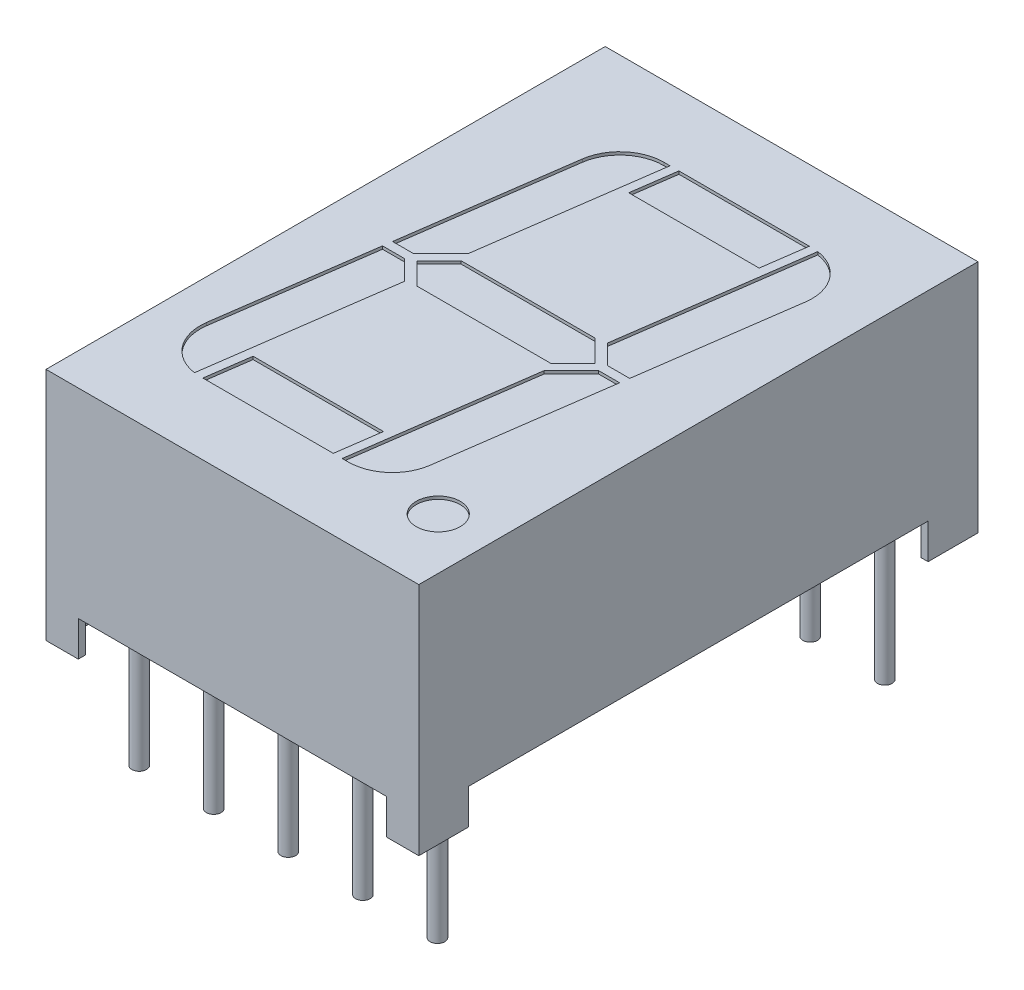
from build123d import *

# Parameters (mm, degrees)
SKETCH1_W          = 12.7
SKETCH1_H          = 19.05
EXTRUDE2_DEPTH     = 8
SKETCH2_W          = 10.5
SKETCH2_H          = 1.2
CUT_EXTRUDE2_DEPTH = 20.05
SKETCH3_W          = 15.65
SKETCH3_H          = 1.2
CUT_EXTRUDE3_DEPTH = 13.7
SKETCH5_R          = 0.25
EXTRUDE3_DEPTH     = 1.2
SKETCH5_5_R        = 0.25
EXTRUDE4_DEPTH     = 4
SKETCH1_4_R        = 0.75
CUT_EXTRUDE4_DEPTH = 0.1
SKETCH5_6_W        = 0.85
SKETCH5_6_H        = 1.45
CUT_EXTRUDE6_DEPTH = 1.2
SKETCH6_W          = 0.025316456
SKETCH6_H          = 0.026582279
CUT_EXTRUDE7_DEPTH = 0.01


with BuildPart() as part:
    # Sketch1 → Extrude2 (new body)
    with BuildSketch(Plane(origin=(0, 0, 0), x_dir=(1, 0, 0), z_dir=(0, 1, 0))):
        Rectangle(SKETCH1_W, SKETCH1_H)
    extrude(amount=-EXTRUDE2_DEPTH)

    # Sketch2 → Cut-Extrude2 (cut, through all)
    with BuildSketch(Plane.XY.offset(9.525)):
        with Locations((0, -7.4)):
            Rectangle(SKETCH2_W, SKETCH2_H)
    extrude(amount=-CUT_EXTRUDE2_DEPTH, mode=Mode.SUBTRACT)

    # Sketch3 → Cut-Extrude3 (cut, through all)
    with BuildSketch(Plane(origin=(6.35, 0, 0), x_dir=(0, 0, -1), z_dir=(1, 0, 0))):
        with Locations((0, -7.4)):
            Rectangle(SKETCH3_W, SKETCH3_H)
    extrude(amount=-CUT_EXTRUDE3_DEPTH, mode=Mode.SUBTRACT)

    # Sketch5 → Extrude3 (add)
    with BuildSketch(Plane.XZ.offset(8)):
        with Locations((-5.08, 7.62)):
            Circle(SKETCH5_R)
        with Locations((-2.54, 7.62)):
            Circle(SKETCH5_R)
        with Locations((0, 7.62)):
            Circle(SKETCH5_R)
        with Locations((2.54, 7.62)):
            Circle(SKETCH5_R)
        with Locations((5.08, 7.62)):
            Circle(SKETCH5_R)
        with Locations(Location((5.08, -7.62, 0), (0, 0, 180))):  # turned: the seam where the file's is
            Circle(SKETCH5_R)
        with Locations(Location((2.54, -7.62, 0), (0, 0, 180))):  # turned: the seam where the file's is
            Circle(SKETCH5_R)
        with Locations(Location((0, -7.62, 0), (0, 0, 180))):  # turned: the seam where the file's is
            Circle(SKETCH5_R)
        with Locations(Location((-2.54, -7.62, 0), (0, 0, 180))):  # turned: the seam where the file's is
            Circle(SKETCH5_R)
        with Locations(Location((-5.08, -7.62, 0), (0, 0, 180))):  # turned: the seam where the file's is
            Circle(SKETCH5_R)
    extrude(amount=-EXTRUDE3_DEPTH)

    # Sketch5_5 → Extrude4 (add)
    with BuildSketch(Plane.XZ.offset(8)):
        with Locations((-5.08, 7.62)):
            Circle(SKETCH5_5_R)
        with Locations((-2.54, 7.62)):
            Circle(SKETCH5_5_R)
        with Locations((0, 7.62)):
            Circle(SKETCH5_5_R)
        with Locations((2.54, 7.62)):
            Circle(SKETCH5_5_R)
        with Locations((5.08, 7.62)):
            Circle(SKETCH5_5_R)
        with Locations(Location((5.08, -7.62, 0), (0, 0, 180))):  # turned: the seam where the file's is
            Circle(SKETCH5_5_R)
        with Locations(Location((2.54, -7.62, 0), (0, 0, 180))):  # turned: the seam where the file's is
            Circle(SKETCH5_5_R)
        with Locations(Location((0, -7.62, 0), (0, 0, 180))):  # turned: the seam where the file's is
            Circle(SKETCH5_5_R)
        with Locations(Location((-2.54, -7.62, 0), (0, 0, 180))):  # turned: the seam where the file's is
            Circle(SKETCH5_5_R)
        with Locations(Location((-5.08, -7.62, 0), (0, 0, 180))):  # turned: the seam where the file's is
            Circle(SKETCH5_5_R)
    extrude(amount=EXTRUDE4_DEPTH)

    # Sketch1_4 → Cut-Extrude4 (cut)
    with BuildSketch(Plane(origin=(0, 0, 0), x_dir=(1, 0, 0), z_dir=(0, 1, 0))):
        Polygon((-1.633862278, 5.61), (2.809378503, 5.61), (3.020188437, 7.11), (-1.423052344, 7.11), align=None)
        with BuildLine():
            Line((3.112326738, 5.61), (2.43839288, 0.814681459))
            Line((2.43839288, 0.814681459), (2.503074451, 0.75))
            Line((2.503074451, 0.75), (3.944043726, 0.75))
            Line((3.944043726, 0.75), (4.597729021, 5.401241628))
            ThreePointArc((4.597729021, 5.401241628), (4.310279226, 6.512723567), (3.32108511, 7.095402283))
            Line((3.32108511, 7.095402283), (3.112326738, 5.61))
        make_face()
        with BuildLine():
            Line((2.171957051, -1.081119824), (1.535468429, -5.61))
            Line((1.535468429, -5.61), (1.324658495, -7.11))
            Line((1.324658495, -7.11), (1.535468429, -7.11))
            ThreePointArc((1.535468429, -7.11), (2.519557461, -6.742063946), (3.020870712, -5.818758372))
            Line((3.020870712, -5.818758372), (3.733233792, -0.75))
            Line((3.733233792, -0.75), (2.503076304, -0.75))
            Line((2.503076304, -0.75), (2.171957051, -1.081119824))
        make_face()
        Polygon((3.103075271, -0.15), (2.503076304, -0.75), (3.733233792, -0.75), (3.817557766, -0.15), align=None)
        Polygon((3.103075485, 0.15), (3.859719753, 0.15), (3.944043726, 0.75), (2.503074451, 0.75), align=None)
        Polygon((1.02171026, -7.11), (1.232520194, -5.61), (-3.210720587, -5.61), (-3.421530521, -7.11), align=None)
        with BuildLine():
            Line((-3.722427194, -7.095402283), (-3.513668822, -5.61))
            Line((-3.513668822, -5.61), (-2.839734964, -0.814681459))
            Line((-2.839734964, -0.814681459), (-2.904416535, -0.75))
            Line((-2.904416535, -0.75), (-4.34538581, -0.75))
            Line((-4.34538581, -0.75), (-4.999071105, -5.401241628))
            ThreePointArc((-4.999071105, -5.401241628), (-4.711621309, -6.512723567), (-3.722427194, -7.095402283))
        make_face()
        Polygon((-4.34538581, -0.75), (-2.904416535, -0.75), (-3.504417568, -0.15), (-4.261061836, -0.15), align=None)
        Polygon((-3.504417354, 0.15), (-2.904418388, 0.75), (-4.134575876, 0.75), (-4.218899849, 0.15), align=None)
        with BuildLine():
            Line((-2.904418388, 0.75), (-2.573299135, 1.081119824))
            Line((-2.573299135, 1.081119824), (-1.936810513, 5.61))
            Line((-1.936810513, 5.61), (-1.726000579, 7.11))
            Line((-1.726000579, 7.11), (-1.936810513, 7.11))
            ThreePointArc((-1.936810513, 7.11), (-2.920899544, 6.742063946), (-3.422212796, 5.818758372))
            Line((-3.422212796, 5.818758372), (-4.134575876, 0.75))
            Line((-4.134575876, 0.75), (-2.904418388, 0.75))
        make_face()
        Polygon((2.078812601, -0.75), (2.241333309, -0.587479012), (2.38611412, 0.442696426), (2.078810017, 0.75), (-2.480154685, 0.75), (-2.642675393, 0.587479012), (-2.787456204, -0.442696426), (-2.4801521, -0.75), align=None)
        Polygon((2.38611412, 0.442696426), (2.241333309, -0.587479012), (2.828811309, 0), align=None)
        Polygon((-3.230153393, 0), (-2.787456204, -0.442696426), (-2.642675393, 0.587479012), align=None)
        with Locations(Location((4.597729021, -7.11, 0), (0, 0, 270))):  # turned: the seam where the file's is
            Circle(SKETCH1_4_R)
    extrude(amount=-CUT_EXTRUDE4_DEPTH, mode=Mode.SUBTRACT)

    # Sketch5_6 → Cut-Extrude6 (cut)
    with BuildSketch(Plane.XZ.offset(8)):
        with Locations((-5.675, 8.55)):
            Rectangle(SKETCH5_6_W, SKETCH5_6_H)
        with Locations((5.675, 8.55)):
            Rectangle(SKETCH5_6_W, SKETCH5_6_H)
        with Locations((5.675, -8.55)):
            Rectangle(SKETCH5_6_W, SKETCH5_6_H)
        with Locations((-5.675, -8.55)):
            Rectangle(SKETCH5_6_W, SKETCH5_6_H)
    extrude(amount=-CUT_EXTRUDE6_DEPTH, mode=Mode.SUBTRACT)

    # Sketch6 → Cut-Extrude7 (cut)
    with BuildSketch(Plane.XZ.offset(6.8)):
        Polygon((-0.572151899, -6.266957949), (-0.595609177, -6.341641494), (-0.620352057, -6.341641494), (-0.636768196, -6.291305259), (-0.652294304, -6.341641494), (-0.678026108, -6.341641494), (-0.701265823, -6.266957949), (-0.676087816, -6.266957949), (-0.663093354, -6.318441335), (-0.646677215, -6.266957949), (-0.625178006, -6.266957949), (-0.608860759, -6.318441335), (-0.596044304, -6.266957949), align=None)
        Polygon((-0.437974684, -6.266957949), (-0.461431962, -6.341641494), (-0.486174842, -6.341641494), (-0.502590981, -6.291305259), (-0.518117089, -6.341641494), (-0.543848892, -6.341641494), (-0.567088608, -6.266957949), (-0.541910601, -6.266957949), (-0.528916139, -6.318441335), (-0.5125, -6.266957949), (-0.491000791, -6.266957949), (-0.474683544, -6.318441335), (-0.461867089, -6.266957949), align=None)
        Polygon((-0.303797468, -6.266957949), (-0.327254747, -6.341641494), (-0.351997627, -6.341641494), (-0.368413766, -6.291305259), (-0.383939873, -6.341641494), (-0.409671677, -6.341641494), (-0.432911392, -6.266957949), (-0.407733386, -6.266957949), (-0.394738924, -6.318441335), (-0.378322785, -6.266957949), (-0.356823576, -6.266957949), (-0.340506329, -6.318441335), (-0.327689873, -6.266957949), align=None)
        with Locations((-0.275949367, -6.328350355)):
            Rectangle(SKETCH6_W, SKETCH6_H)
        with BuildLine():
            add(Edge.make_bspline(
                [(-0.159493671, -6.310470607), (-0.15953016, -6.311692749), (-0.159601812, -6.314092627), (-0.16021153, -6.317600205), (-0.161205016, -6.32092491), (-0.162579134, -6.324087571), (-0.164367936, -6.32706619), (-0.166577526, -6.329846467), (-0.169141939, -6.332481267), (-0.172108149, -6.334887397), (-0.175388259, -6.337091773), (-0.178985835, -6.338988773), (-0.182864539, -6.340585255), (-0.187013125, -6.341923807), (-0.191459564, -6.342912387), (-0.196177094, -6.343636333), (-0.201170512, -6.344109663), (-0.20459409, -6.344151629), (-0.206348892, -6.344173139)],
                knots=[0, 0, 0, 0, 0.907352243, 1.781736951, 2.63548328, 3.47985091, 4.336556021, 5.208523475, 6.112432747, 7.062451073, 8.040435374, 9.043840564, 10.077958095, 11.152835584, 12.277940427, 13.457536469, 14.696825396, 16, 16, 16, 16], degree=3))
            add(Edge.make_bspline(
                [(-0.206348892, -6.344173139), (-0.208367148, -6.344149067), (-0.21227633, -6.344102443), (-0.217939855, -6.343673844), (-0.223207892, -6.343027704), (-0.228103607, -6.342061162), (-0.232708206, -6.340860397), (-0.237141474, -6.339569106), (-0.241422786, -6.33810469), (-0.244195876, -6.337004532), (-0.24556962, -6.336459532)],
                knots=[0, 0, 0, 0, 1.203215828, 2.33052265, 3.384689099, 4.366106119, 5.303329643, 6.221311756, 7.118865988, 8, 8, 8, 8], degree=3))
            Line((-0.24556962, -6.336459532), (-0.24556962, -6.31252757))
            Line((-0.24556962, -6.31252757), (-0.242721519, -6.31252757))
            add(Edge.make_bspline(
                [(-0.242721519, -6.31252757), (-0.241356205, -6.313609025), (-0.238633592, -6.315765585), (-0.234200359, -6.318528191), (-0.229552713, -6.320930354), (-0.224707243, -6.322904355), (-0.219810398, -6.324490679), (-0.21493502, -6.325584207), (-0.210169433, -6.326331556), (-0.207010864, -6.326412062), (-0.205458861, -6.32645162)],
                knots=[0, 0, 0, 0, 1.030622468, 2.055194264, 3.087043286, 4.125157485, 5.149848264, 6.130935704, 7.081611712, 8, 8, 8, 8], degree=3))
            add(Edge.make_bspline(
                [(-0.205458861, -6.32645162), (-0.205030085, -6.326450697), (-0.204112108, -6.326448719), (-0.202650581, -6.326320992), (-0.20099877, -6.326225415), (-0.199226261, -6.326018231), (-0.197429535, -6.325796371), (-0.195767134, -6.325421446), (-0.194257539, -6.325056578), (-0.193351018, -6.324688581), (-0.192919304, -6.324513329)],
                knots=[0, 0, 0, 0, 0.806402781, 1.726445712, 2.758724871, 3.919014682, 5.083870887, 6.16165551, 7.124521387, 8, 8, 8, 8], degree=3))
            add(Edge.make_bspline(
                [(-0.192919304, -6.324513329), (-0.192439741, -6.324285187), (-0.191497298, -6.32383684), (-0.190203698, -6.323026521), (-0.189036018, -6.322143056), (-0.187978647, -6.321178126), (-0.187104366, -6.320012376), (-0.186480499, -6.318603703), (-0.186135606, -6.316954685), (-0.186096583, -6.315779482), (-0.186075949, -6.315158107)],
                knots=[0, 0, 0, 0, 1.024747072, 2.013846092, 2.940605744, 3.850156746, 4.769278501, 5.73222711, 6.800942666, 8, 8, 8, 8], degree=3))
            add(Edge.make_bspline(
                [(-0.186075949, -6.315158107), (-0.186107794, -6.31461247), (-0.18617041, -6.313539586), (-0.186747603, -6.312004472), (-0.187657041, -6.310595304), (-0.188938631, -6.309326529), (-0.190531807, -6.308176995), (-0.192474191, -6.30719469), (-0.194724312, -6.306321502), (-0.196368382, -6.305903525), (-0.197231013, -6.305684215)],
                knots=[0, 0, 0, 0, 0.82557554, 1.623324704, 2.456147571, 3.35491006, 4.343819762, 5.427079081, 6.650009487, 8, 8, 8, 8], degree=3))
            add(Edge.make_bspline(
                [(-0.197231013, -6.305684215), (-0.199199639, -6.305235975), (-0.203238649, -6.304316325), (-0.209388473, -6.30317757), (-0.215516824, -6.30190271), (-0.219469591, -6.300696067), (-0.221400316, -6.300106683)],
                knots=[0, 0, 0, 0, 0.976100998, 2.002656142, 3.024398856, 4, 4, 4, 4], degree=3))
            add(Edge.make_bspline(
                [(-0.221400316, -6.300106683), (-0.222438835, -6.299753693), (-0.224460408, -6.299066565), (-0.227351919, -6.297904905), (-0.230013147, -6.296635076), (-0.23245286, -6.295279521), (-0.234653549, -6.293806981), (-0.236647817, -6.292265603), (-0.238410933, -6.290625564), (-0.239957738, -6.288885797), (-0.241282641, -6.287035094), (-0.242435025, -6.285089897), (-0.243417646, -6.283034477), (-0.244195684, -6.280864254), (-0.244820323, -6.278590599), (-0.245239305, -6.276212887), (-0.245538322, -6.273729758), (-0.245559046, -6.272035373), (-0.24556962, -6.271170766)],
                knots=[0, 0, 0, 0, 1.287047841, 2.5053592, 3.654260482, 4.74538952, 5.777514103, 6.75871007, 7.700244599, 8.599107454, 9.48590269, 10.366941872, 11.24940663, 12.154970331, 13.068988358, 14.012872203, 14.986013017, 16, 16, 16, 16], degree=3))
            add(Edge.make_bspline(
                [(-0.24556962, -6.271170766), (-0.245532318, -6.270014621), (-0.245458909, -6.267739349), (-0.24485748, -6.264410304), (-0.24383089, -6.261261568), (-0.242444827, -6.258258105), (-0.240616199, -6.255445019), (-0.238431404, -6.252766471), (-0.235807357, -6.25029488), (-0.232830235, -6.247994546), (-0.229542851, -6.245915148), (-0.226003867, -6.244084591), (-0.222234578, -6.24254794), (-0.218249032, -6.241274046), (-0.214030563, -6.240319375), (-0.20959333, -6.239600443), (-0.204919541, -6.239187262), (-0.20172812, -6.239136011), (-0.200098892, -6.239109848)],
                knots=[0, 0, 0, 0, 0.894990994, 1.761326291, 2.609044902, 3.454222546, 4.315366365, 5.200560057, 6.125081389, 7.100429509, 8.110379559, 9.133447974, 10.182136699, 11.259192205, 12.370181258, 13.528580438, 14.738335141, 16, 16, 16, 16], degree=3))
            add(Edge.make_bspline(
                [(-0.200098892, -6.239109848), (-0.198430198, -6.239132001), (-0.19509564, -6.239176269), (-0.1901143, -6.239554826), (-0.185159872, -6.240107138), (-0.180297448, -6.240956378), (-0.175605285, -6.24192461), (-0.17118617, -6.243023883), (-0.167106618, -6.244261389), (-0.164532965, -6.245215791), (-0.163291139, -6.245676304)],
                knots=[0, 0, 0, 0, 1.065407564, 2.129008667, 3.188544425, 4.247469455, 5.279542408, 6.247502114, 7.154394069, 8, 8, 8, 8], degree=3))
            Line((-0.163291139, -6.245676304), (-0.163291139, -6.268223772))
            Line((-0.163291139, -6.268223772), (-0.166119462, -6.268223772))
            add(Edge.make_bspline(
                [(-0.166119462, -6.268223772), (-0.167192966, -6.267424484), (-0.169383743, -6.265793319), (-0.173033347, -6.263691583), (-0.177000967, -6.261751492), (-0.181282594, -6.260059835), (-0.185742374, -6.258601828), (-0.190325133, -6.25758227), (-0.194951348, -6.256940562), (-0.198053052, -6.256867774), (-0.19960443, -6.256831367)],
                knots=[0, 0, 0, 0, 0.892265782, 1.820912499, 2.804518821, 3.836954028, 4.889985052, 5.931488012, 6.965393252, 8, 8, 8, 8], degree=3))
            add(Edge.make_bspline(
                [(-0.19960443, -6.256831367), (-0.200700035, -6.25685327), (-0.202897679, -6.256897203), (-0.20616687, -6.257282089), (-0.209407348, -6.257920942), (-0.21144203, -6.258736994), (-0.212460443, -6.259145449)],
                knots=[0, 0, 0, 0, 0.999122297, 2.004111588, 3.001004448, 4, 4, 4, 4], degree=3))
            add(Edge.make_bspline(
                [(-0.212460443, -6.259145449), (-0.212894173, -6.259346628), (-0.213761342, -6.259748852), (-0.214968884, -6.260528478), (-0.216089856, -6.261444821), (-0.217085439, -6.262497578), (-0.217929873, -6.263665932), (-0.218548899, -6.264933514), (-0.218923392, -6.266297396), (-0.218965739, -6.267232495), (-0.218987342, -6.267709532)],
                knots=[0, 0, 0, 0, 1.004925302, 2.009180302, 3.014392739, 4.04465309, 5.049195417, 6.035570224, 6.99785458, 8, 8, 8, 8], degree=3))
            add(Edge.make_bspline(
                [(-0.218987342, -6.267709532), (-0.218952904, -6.268347697), (-0.218887095, -6.269567173), (-0.218280511, -6.271282968), (-0.217295678, -6.272761402), (-0.216135073, -6.273756322), (-0.215017943, -6.27445376), (-0.213982284, -6.274964271), (-0.212773057, -6.27544763), (-0.211401809, -6.275945098), (-0.209865482, -6.276436286), (-0.208156925, -6.276911832), (-0.206274208, -6.277361128), (-0.204958333, -6.277647319), (-0.204272152, -6.277796557)],
                knots=[0, 0, 0, 0, 1.173816843, 2.243057204, 3.312297565, 4.415174738, 5.03266065, 5.73970059, 6.541434878, 7.433956553, 8.430083051, 9.515931566, 10.70464786, 12, 12, 12, 12], degree=3))
            add(Edge.make_bspline(
                [(-0.204272152, -6.277796557), (-0.202439229, -6.278172002), (-0.198844263, -6.278908373), (-0.193445039, -6.280020738), (-0.187940051, -6.281286097), (-0.184268899, -6.282438093), (-0.182357595, -6.283037854)],
                knots=[0, 0, 0, 0, 0.995749986, 1.952994291, 2.934271555, 4, 4, 4, 4], degree=3))
            add(Edge.make_bspline(
                [(-0.182357595, -6.283037854), (-0.181411107, -6.283357213), (-0.179559623, -6.283981931), (-0.176918075, -6.285066615), (-0.174469022, -6.286248704), (-0.172190751, -6.28747119), (-0.17012867, -6.288834407), (-0.168235447, -6.290249054), (-0.166552428, -6.291777163), (-0.165054478, -6.293390021), (-0.163736077, -6.295100454), (-0.162601114, -6.296938556), (-0.161637968, -6.298893085), (-0.160829836, -6.300966157), (-0.16025182, -6.303173225), (-0.159817762, -6.305499525), (-0.15952694, -6.307944841), (-0.159504884, -6.309619287), (-0.159493671, -6.310470607)],
                knots=[0, 0, 0, 0, 1.237386967, 2.420528625, 3.534815053, 4.605870898, 5.620827102, 6.594482803, 7.531295079, 8.432978826, 9.318460435, 10.202471551, 11.10474705, 12.014900263, 12.954095338, 13.926516828, 14.945802342, 16, 16, 16, 16], degree=3))
        make_face()
        with BuildLine():
            Line((-0.067088608, -6.341641494), (-0.091139241, -6.341641494))
            Line((-0.091139241, -6.341641494), (-0.091139241, -6.333809215))
            add(Edge.make_bspline(
                [(-0.091139241, -6.333809215), (-0.092232496, -6.334617882), (-0.094340276, -6.336176981), (-0.097514015, -6.338255745), (-0.100542736, -6.340038907), (-0.103464337, -6.34158106), (-0.106479693, -6.342771907), (-0.109707195, -6.343593763), (-0.113209459, -6.344094883), (-0.115636434, -6.344146474), (-0.116890823, -6.344173139)],
                knots=[0, 0, 0, 0, 1.150906677, 2.218931226, 3.20955724, 4.125565256, 5.012676028, 5.946647191, 6.938718366, 8, 8, 8, 8], degree=3))
            add(Edge.make_bspline(
                [(-0.116890823, -6.344173139), (-0.117907168, -6.34415041), (-0.119886286, -6.34410615), (-0.122763616, -6.343761412), (-0.125470927, -6.343223266), (-0.127987077, -6.34241741), (-0.130352422, -6.341443293), (-0.132503941, -6.340184206), (-0.13449163, -6.338724869), (-0.136295007, -6.337047933), (-0.137885627, -6.335126971), (-0.139272677, -6.333004221), (-0.140448489, -6.330669582), (-0.141390127, -6.328118215), (-0.142145061, -6.325359771), (-0.142669038, -6.322380564), (-0.142989618, -6.319193425), (-0.143021559, -6.316998296), (-0.143037975, -6.315870133)],
                knots=[0, 0, 0, 0, 1.108935798, 2.159418225, 3.158520219, 4.116592843, 5.038730546, 5.944611115, 6.829677354, 7.725673622, 8.624842385, 9.544872214, 10.487719724, 11.471363217, 12.50822837, 13.604887271, 14.769056852, 16, 16, 16, 16], degree=3))
            Line((-0.143037975, -6.315870133), (-0.143037975, -6.266957949))
            Line((-0.143037975, -6.266957949), (-0.118987342, -6.266957949))
            Line((-0.118987342, -6.266957949), (-0.118987342, -6.304537063))
            add(Edge.make_bspline(
                [(-0.118987342, -6.304537063), (-0.118985706, -6.305453534), (-0.118982576, -6.30720775), (-0.118900237, -6.309713556), (-0.118779336, -6.311981729), (-0.118640631, -6.314023758), (-0.118387615, -6.315870508), (-0.118009906, -6.317536669), (-0.11753908, -6.319056271), (-0.117074761, -6.319962973), (-0.116851266, -6.320399405)],
                knots=[0, 0, 0, 0, 1.361401701, 2.605856924, 3.723918663, 4.735739235, 5.645738665, 6.489217889, 7.27279937, 8, 8, 8, 8], degree=3))
            add(Edge.make_bspline(
                [(-0.116851266, -6.320399405), (-0.116621226, -6.320798053), (-0.116168987, -6.32158176), (-0.115249176, -6.322588908), (-0.114173193, -6.323425814), (-0.112903555, -6.324098458), (-0.111410474, -6.324582162), (-0.109678473, -6.324928909), (-0.107692458, -6.325142732), (-0.106283538, -6.325170895), (-0.105537975, -6.325185797)],
                knots=[0, 0, 0, 0, 0.849057291, 1.669173542, 2.503217716, 3.359509317, 4.311793648, 5.394940091, 6.621469141, 8, 8, 8, 8], degree=3))
            add(Edge.make_bspline(
                [(-0.105537975, -6.325185797), (-0.10499671, -6.32516834), (-0.103883832, -6.325132446), (-0.102178621, -6.324902518), (-0.100389592, -6.324540862), (-0.097875395, -6.323881838), (-0.09469925, -6.32270266), (-0.092335111, -6.321343858), (-0.091139241, -6.320656525)],
                knots=[0, 0, 0, 0, 0.638164724, 1.312110757, 2.025558264, 2.789159289, 4.375836335, 6, 6, 6, 6], degree=3))
            Line((-0.091139241, -6.320656525), (-0.091139241, -6.266957949))
            Line((-0.091139241, -6.266957949), (-0.067088608, -6.266957949))
            Line((-0.067088608, -6.266957949), (-0.067088608, -6.341641494))
        make_face()
        with BuildLine():
            Line((0.030379747, -6.341641494), (0.006329114, -6.341641494))
            Line((0.006329114, -6.341641494), (0.006329114, -6.30406238))
            add(Edge.make_bspline(
                [(0.006329114, -6.30406238), (0.00630879, -6.302531906), (0.006268255, -6.299479494), (0.005934675, -6.295722718), (0.005600966, -6.292874928), (0.005224143, -6.291038861), (0.004793956, -6.289490525), (0.00438151, -6.288604787), (0.004193038, -6.288200038)],
                knots=[0, 0, 0, 0, 1.709235885, 3.408940626, 4.211008593, 4.910095588, 5.501954032, 6, 6, 6, 6], degree=3))
            add(Edge.make_bspline(
                [(0.004193038, -6.288200038), (0.00394861, -6.287801915), (0.003469373, -6.28702134), (0.002531558, -6.286009318), (0.001434909, -6.285173105), (0.000156185, -6.284508155), (-0.001328468, -6.284022257), (-0.003041142, -6.283635598), (-0.005027113, -6.283467038), (-0.006434481, -6.283432128), (-0.007179589, -6.283413645)],
                knots=[0, 0, 0, 0, 0.860145871, 1.686437142, 2.528070002, 3.393017362, 4.331453407, 5.402595683, 6.624848233, 8, 8, 8, 8], degree=3))
            add(Edge.make_bspline(
                [(-0.007179589, -6.283413645), (-0.008311478, -6.283470226), (-0.010622712, -6.283585759), (-0.013484003, -6.284299351), (-0.015810878, -6.285111648), (-0.017656499, -6.285885885), (-0.019573028, -6.28684051), (-0.020856452, -6.287567584), (-0.021518987, -6.287942918)],
                knots=[0, 0, 0, 0, 1.338419466, 2.732951426, 3.468143565, 4.254837763, 5.099104234, 6, 6, 6, 6], degree=3))
            Line((-0.021518987, -6.287942918), (-0.021518987, -6.341641494))
            Line((-0.021518987, -6.341641494), (-0.04556962, -6.341641494))
            Line((-0.04556962, -6.341641494), (-0.04556962, -6.266957949))
            Line((-0.04556962, -6.266957949), (-0.021518987, -6.266957949))
            Line((-0.021518987, -6.266957949), (-0.021518987, -6.274790228))
            add(Edge.make_bspline(
                [(-0.021518987, -6.274790228), (-0.02046175, -6.27398379), (-0.018403774, -6.272414011), (-0.015227022, -6.270380601), (-0.01215631, -6.268570745), (-0.009101788, -6.267058611), (-0.005977291, -6.26586001), (-0.00270966, -6.265044407), (0.000707053, -6.264501459), (0.003043726, -6.264451647), (0.004232595, -6.264426304)],
                knots=[0, 0, 0, 0, 1.126064518, 2.191951536, 3.19307265, 4.144813015, 5.076393104, 6.021983703, 6.993610568, 8, 8, 8, 8], degree=3))
            add(Edge.make_bspline(
                [(0.004232595, -6.264426304), (0.005228866, -6.264451693), (0.007173765, -6.264501257), (0.010008526, -6.264810966), (0.012679947, -6.26536163), (0.015172222, -6.26615946), (0.017514838, -6.267145073), (0.019676795, -6.268376583), (0.021668821, -6.269835023), (0.02349739, -6.271495964), (0.025127571, -6.273385922), (0.026547057, -6.275502295), (0.02771848, -6.277851024), (0.028727312, -6.28039816), (0.029461537, -6.283175931), (0.029987988, -6.286166697), (0.030338418, -6.289371879), (0.030365695, -6.291587779), (0.030379747, -6.29272931)],
                knots=[0, 0, 0, 0, 1.088441561, 2.124831547, 3.110816719, 4.062969431, 4.979391633, 5.88258537, 6.774334107, 7.671621258, 8.575503974, 9.49441354, 10.447872957, 11.437639084, 12.482478955, 13.580222388, 14.753440527, 16, 16, 16, 16], degree=3))
            Line((0.030379747, -6.29272931), (0.030379747, -6.341641494))
        make_face()
        Polygon((0.125316456, -6.341641494), (0.053164557, -6.341641494), (0.053164557, -6.241641494), (0.078481013, -6.241641494), (0.078481013, -6.322654152), (0.125316456, -6.322654152), align=None)
        Polygon((0.212658228, -6.341641494), (0.140506329, -6.341641494), (0.140506329, -6.241641494), (0.212658228, -6.241641494), (0.212658228, -6.260628835), (0.165822785, -6.260628835), (0.165822785, -6.278350354), (0.208860759, -6.278350354), (0.208860759, -6.297337696), (0.165822785, -6.297337696), (0.165822785, -6.322654152), (0.212658228, -6.322654152), align=None)
        with BuildLine():
            add(Edge.make_bspline(
                [(0.329113924, -6.291740386), (0.329094609, -6.292888075), (0.329056357, -6.295160961), (0.328761165, -6.298525768), (0.32823514, -6.301791443), (0.327555959, -6.304975692), (0.326633453, -6.308054619), (0.325551739, -6.311062196), (0.324242093, -6.31396769), (0.322737241, -6.316769124), (0.321087768, -6.319441227), (0.319313019, -6.321961436), (0.31746724, -6.324344654), (0.315477927, -6.326539548), (0.313398746, -6.328581567), (0.311223217, -6.330472381), (0.308918153, -6.332175812), (0.30731099, -6.333198697), (0.30650712, -6.333710323)],
                knots=[0, 0, 0, 0, 1.105570398, 2.18947457, 3.250358341, 4.290584537, 5.323553275, 6.344225964, 7.367641686, 8.3905646, 9.405808457, 10.390761353, 11.358902336, 12.307789878, 13.241960776, 14.165076779, 15.082208636, 16, 16, 16, 16], degree=3))
            add(Edge.make_bspline(
                [(0.30650712, -6.333710323), (0.305267899, -6.334422492), (0.302783134, -6.335850466), (0.298799188, -6.337518597), (0.294668069, -6.338926553), (0.290309515, -6.339974743), (0.285663167, -6.340703476), (0.28066851, -6.341266526), (0.275267382, -6.341566891), (0.2715325, -6.341616059), (0.269600475, -6.341641494)],
                knots=[0, 0, 0, 0, 0.896298978, 1.797171328, 2.70531317, 3.633678302, 4.606491125, 5.655688921, 6.787306437, 8, 8, 8, 8], degree=3))
            Line((0.269600475, -6.341641494), (0.234177215, -6.341641494))
            Line((0.234177215, -6.341641494), (0.234177215, -6.241641494))
            Line((0.234177215, -6.241641494), (0.270609177, -6.241641494))
            add(Edge.make_bspline(
                [(0.270609177, -6.241641494), (0.272587901, -6.241658189), (0.276404614, -6.241690392), (0.281915032, -6.242106361), (0.287013411, -6.242705881), (0.291697991, -6.243632573), (0.296006397, -6.244741224), (0.299937419, -6.246104259), (0.303549308, -6.247602531), (0.305728136, -6.248876279), (0.306784019, -6.249493551)],
                knots=[0, 0, 0, 0, 1.267192274, 2.444256634, 3.537982003, 4.553396635, 5.500903572, 6.385021601, 7.217363933, 8, 8, 8, 8], degree=3))
            add(Edge.make_bspline(
                [(0.306784019, -6.249493551), (0.307634972, -6.250030091), (0.309327097, -6.251097005), (0.311728312, -6.252878857), (0.313957739, -6.254834934), (0.316086242, -6.256886752), (0.318066056, -6.25908964), (0.319909269, -6.261428344), (0.321613036, -6.263906451), (0.323171192, -6.266515871), (0.324591277, -6.26924611), (0.325783356, -6.272118456), (0.326822718, -6.275101329), (0.327668801, -6.278200268), (0.32832513, -6.281417658), (0.328771214, -6.284755138), (0.329054647, -6.288208327), (0.329093999, -6.29055312), (0.329113924, -6.291740386)],
                knots=[0, 0, 0, 0, 0.964043478, 1.917004671, 2.862223898, 3.805158963, 4.749279098, 5.698713747, 6.657523689, 7.629652222, 8.610369353, 9.604453025, 10.607693792, 11.636365947, 12.681120053, 13.752669011, 14.862083412, 16, 16, 16, 16], degree=3))
        make_face()
        with BuildLine():
            add(Edge.make_bspline(
                [(0.302531646, -6.291582158), (0.302521175, -6.290777445), (0.302500636, -6.289198953), (0.302312313, -6.286882777), (0.302041725, -6.284656728), (0.301652591, -6.282513095), (0.301112159, -6.280462947), (0.300479977, -6.278501378), (0.299752887, -6.276622455), (0.298871957, -6.274844795), (0.297898133, -6.273136458), (0.296750689, -6.271550931), (0.295502338, -6.270038048), (0.294124055, -6.268610062), (0.292581114, -6.267304166), (0.290921012, -6.26607409), (0.289120654, -6.264945764), (0.287847665, -6.264285715), (0.287203323, -6.26395162)],
                knots=[0, 0, 0, 0, 1.152052275, 2.259818351, 3.325348653, 4.362224493, 5.376551665, 6.358740615, 7.312387502, 8.258104984, 9.197203025, 10.124507262, 11.056413058, 12.004389423, 12.961766972, 13.947352551, 14.961020569, 16, 16, 16, 16], degree=3))
            add(Edge.make_bspline(
                [(0.287203323, -6.26395162), (0.286528425, -6.263644908), (0.285190731, -6.263036984), (0.283119908, -6.262305791), (0.281030524, -6.261732956), (0.278828925, -6.261302097), (0.276359165, -6.260980166), (0.273433583, -6.260782908), (0.269977674, -6.260640739), (0.267490959, -6.260632987), (0.266159019, -6.260628835)],
                knots=[0, 0, 0, 0, 0.826967603, 1.639107464, 2.447640171, 3.242670507, 4.14065217, 5.225198036, 6.513753944, 8, 8, 8, 8], degree=3))
            Line((0.266159019, -6.260628835), (0.259493671, -6.260628835))
            Line((0.259493671, -6.260628835), (0.259493671, -6.322654152))
            Line((0.259493671, -6.322654152), (0.266159019, -6.322654152))
            add(Edge.make_bspline(
                [(0.266159019, -6.322654152), (0.266917226, -6.322649406), (0.268380993, -6.322640244), (0.27049723, -6.32259713), (0.272463046, -6.322550416), (0.274267852, -6.322433379), (0.275920195, -6.322362879), (0.277406342, -6.322179208), (0.278743292, -6.322044733), (0.280315773, -6.321767011), (0.28217096, -6.321361036), (0.284337749, -6.320677878), (0.286478448, -6.319828304), (0.287866999, -6.319143225), (0.288568038, -6.318797348)],
                knots=[0, 0, 0, 0, 1.186805873, 2.291202465, 3.313317863, 4.264127762, 5.122212376, 5.900577546, 6.607154111, 7.224697658, 8.398873738, 9.57716935, 10.776782771, 12, 12, 12, 12], degree=3))
            add(Edge.make_bspline(
                [(0.288568038, -6.318797348), (0.289153152, -6.31845583), (0.290307072, -6.317782313), (0.291930612, -6.316648262), (0.293438202, -6.315440452), (0.294834679, -6.314152312), (0.296096265, -6.312762926), (0.297252353, -6.31130346), (0.29825774, -6.309743139), (0.299496994, -6.307554313), (0.300744084, -6.304529555), (0.301776483, -6.300556802), (0.302415631, -6.29619789), (0.302491983, -6.293160149), (0.302531646, -6.291582158)],
                knots=[0, 0, 0, 0, 0.755237594, 1.489427721, 2.205882609, 2.908165467, 3.605466573, 4.296695275, 4.981837198, 5.673065901, 7.099889822, 8.61390339, 10.241051878, 12, 12, 12, 12], degree=3))
        make_face(mode=Mode.SUBTRACT)
        with Locations((0.360759494, -6.328350355)):
            Rectangle(SKETCH6_W, SKETCH6_H)
        with BuildLine():
            add(Edge.make_bspline(
                [(0.435403481, -6.344173139), (0.433813364, -6.344151336), (0.43069222, -6.34410854), (0.426120933, -6.343631511), (0.421755567, -6.342914215), (0.417609943, -6.341891896), (0.4136994, -6.340551377), (0.41004445, -6.33888137), (0.406627778, -6.336914175), (0.404565858, -6.335329278), (0.403540348, -6.334541019)],
                knots=[0, 0, 0, 0, 1.123701398, 2.205645569, 3.245398653, 4.249180969, 5.220497262, 6.163202923, 7.086456062, 8, 8, 8, 8], degree=3))
            add(Edge.make_bspline(
                [(0.403540348, -6.334541019), (0.402588713, -6.333686186), (0.400689124, -6.331979826), (0.398221497, -6.329009282), (0.396103421, -6.325720309), (0.394291165, -6.322128656), (0.392859214, -6.318208771), (0.391866679, -6.313958876), (0.391239075, -6.309401547), (0.391173123, -6.306253342), (0.391139241, -6.304635956)],
                knots=[0, 0, 0, 0, 0.916342154, 1.829140869, 2.758848968, 3.716597128, 4.708179637, 5.743612459, 6.840783343, 8, 8, 8, 8], degree=3))
            add(Edge.make_bspline(
                [(0.391139241, -6.304635956), (0.391178001, -6.302932728), (0.391253124, -6.299631648), (0.391916883, -6.294859461), (0.392986496, -6.29044178), (0.394524054, -6.286389872), (0.396454496, -6.28269668), (0.398718989, -6.279324846), (0.401339514, -6.276281922), (0.403346653, -6.274536482), (0.404351266, -6.273662854)],
                knots=[0, 0, 0, 0, 1.171797512, 2.271099083, 3.308930235, 4.294129479, 5.24602549, 6.17106565, 7.084581485, 8, 8, 8, 8], degree=3))
            add(Edge.make_bspline(
                [(0.404351266, -6.273662854), (0.40537705, -6.272894075), (0.407441008, -6.271347232), (0.410840547, -6.26945242), (0.41445276, -6.267847903), (0.418283877, -6.266602017), (0.422264395, -6.26565348), (0.426329936, -6.264926508), (0.430476303, -6.264506483), (0.433266488, -6.264453159), (0.434671677, -6.264426304)],
                knots=[0, 0, 0, 0, 0.952097844, 1.915695341, 2.885641886, 3.886921822, 4.905719434, 5.925883802, 6.95543633, 8, 8, 8, 8], degree=3))
            add(Edge.make_bspline(
                [(0.434671677, -6.264426304), (0.435918404, -6.264443267), (0.438369891, -6.264476624), (0.441970824, -6.264799281), (0.445419409, -6.265329446), (0.448716721, -6.26607304), (0.451889869, -6.266965838), (0.454949341, -6.267997119), (0.457914157, -6.26913506), (0.459814835, -6.270019275), (0.460759494, -6.27045874)],
                knots=[0, 0, 0, 0, 1.107671842, 2.178058178, 3.209662749, 4.206063564, 5.179815947, 6.137646632, 7.07438927, 8, 8, 8, 8], degree=3))
            Line((0.460759494, -6.27045874), (0.460759494, -6.291008582))
            Line((0.460759494, -6.291008582), (0.45741693, -6.291008582))
            add(Edge.make_bspline(
                [(0.45741693, -6.291008582), (0.456918162, -6.290590355), (0.455836226, -6.289683131), (0.454034874, -6.288282119), (0.451901363, -6.286731553), (0.450250156, -6.28584555), (0.449367089, -6.285371715)],
                knots=[0, 0, 0, 0, 0.792878214, 1.719922066, 2.780612869, 4, 4, 4, 4], degree=3))
            add(Edge.make_bspline(
                [(0.449367089, -6.285371715), (0.448439429, -6.284928847), (0.4465324, -6.284018423), (0.443972423, -6.28319888), (0.441783392, -6.282620343), (0.439971509, -6.282367533), (0.438038089, -6.282177185), (0.436702818, -6.28215779), (0.436016614, -6.282147823)],
                knots=[0, 0, 0, 0, 1.33256682, 2.739414054, 3.480190821, 4.267897792, 5.109861573, 6, 6, 6, 6], degree=3))
            add(Edge.make_bspline(
                [(0.436016614, -6.282147823), (0.435251065, -6.282167382), (0.433767468, -6.282205287), (0.431605865, -6.282482209), (0.429587789, -6.282960944), (0.427683381, -6.283599356), (0.425944635, -6.284495596), (0.424302105, -6.285507863), (0.422827629, -6.286762371), (0.421485682, -6.288180112), (0.420298198, -6.289770625), (0.419271446, -6.291497113), (0.418388719, -6.293355005), (0.417686826, -6.295352913), (0.417129316, -6.297482776), (0.416739751, -6.299745586), (0.416497972, -6.302145184), (0.416470029, -6.303791479), (0.416455696, -6.304635956)],
                knots=[0, 0, 0, 0, 1.087094245, 2.106738054, 3.087824582, 4.029427112, 4.95060567, 5.859714611, 6.763601524, 7.690850518, 8.627131371, 9.576106403, 10.539384251, 11.543302637, 12.578856349, 13.662518017, 14.800975475, 16, 16, 16, 16], degree=3))
            add(Edge.make_bspline(
                [(0.416455696, -6.304635956), (0.416470471, -6.305500112), (0.416499177, -6.307179124), (0.416732691, -6.309620735), (0.417148582, -6.311902167), (0.41771983, -6.314027487), (0.418444178, -6.315993505), (0.419349295, -6.317790901), (0.420385652, -6.319447709), (0.42163021, -6.320910321), (0.422994093, -6.322226642), (0.424508985, -6.323362777), (0.426168224, -6.324310922), (0.427950405, -6.325115385), (0.429883445, -6.325693783), (0.431939982, -6.326130475), (0.434129537, -6.326419031), (0.435639891, -6.326440594), (0.436412184, -6.32645162)],
                knots=[0, 0, 0, 0, 1.230336593, 2.390482092, 3.487897344, 4.52859895, 5.520747884, 6.465347575, 7.38981449, 8.296085817, 9.192433006, 10.084246191, 10.984321635, 11.908883871, 12.862027947, 13.850751296, 14.901019963, 16, 16, 16, 16], degree=3))
            add(Edge.make_bspline(
                [(0.436412184, -6.32645162), (0.437138026, -6.326443397), (0.438553028, -6.326427365), (0.440611451, -6.326211299), (0.442565368, -6.325931972), (0.444399915, -6.325490696), (0.446104164, -6.324955812), (0.447669817, -6.324384985), (0.449082423, -6.323780706), (0.449943758, -6.32331309), (0.450356013, -6.323089278)],
                knots=[0, 0, 0, 0, 1.200879421, 2.341068892, 3.423000803, 4.465923194, 5.460027553, 6.378409259, 7.223869634, 8, 8, 8, 8], degree=3))
            add(Edge.make_bspline(
                [(0.450356013, -6.323089278), (0.451064369, -6.322661593), (0.452425742, -6.321839633), (0.454250861, -6.320419174), (0.455894986, -6.319012733), (0.456919091, -6.318055966), (0.45741693, -6.317590861)],
                knots=[0, 0, 0, 0, 1.105932972, 2.12546697, 3.088749538, 4, 4, 4, 4], degree=3))
            Line((0.45741693, -6.317590861), (0.460759494, -6.317590861))
            Line((0.460759494, -6.317590861), (0.460759494, -6.33829893))
            add(Edge.make_bspline(
                [(0.460759494, -6.33829893), (0.459814117, -6.338736472), (0.457923136, -6.339611662), (0.455008359, -6.340764813), (0.452015116, -6.341737692), (0.448963886, -6.342630038), (0.445794254, -6.343328233), (0.442476905, -6.343817463), (0.438995601, -6.344119202), (0.436617185, -6.344154915), (0.435403481, -6.344173139)],
                knots=[0, 0, 0, 0, 0.952024047, 1.90427691, 2.862762905, 3.827874523, 4.80891974, 5.826446878, 6.890837857, 8, 8, 8, 8], degree=3))
        make_face()
        with BuildLine():
            add(Edge.make_bspline(
                [(0.553164557, -6.304339278), (0.553139637, -6.30584411), (0.553091062, -6.308777431), (0.552554854, -6.313050251), (0.551731391, -6.317080693), (0.550598066, -6.32088153), (0.549080213, -6.324424576), (0.547237799, -6.32772053), (0.545064208, -6.330772713), (0.542573889, -6.333562939), (0.539772404, -6.336061131), (0.536698638, -6.338257324), (0.533328772, -6.340064372), (0.529720026, -6.341590922), (0.525830719, -6.342747023), (0.521671624, -6.343564973), (0.517254115, -6.344099305), (0.514215749, -6.344148117), (0.512658228, -6.344173139)],
                knots=[0, 0, 0, 0, 1.120122129, 2.18341868, 3.201215738, 4.181270334, 5.131540819, 6.065757527, 6.988093576, 7.916512302, 8.844931028, 9.778115023, 10.722851943, 11.686686084, 12.691660064, 13.738321946, 14.84062285, 16, 16, 16, 16], degree=3))
            add(Edge.make_bspline(
                [(0.512658228, -6.344173139), (0.51110068, -6.344148199), (0.508062261, -6.344099548), (0.503645127, -6.343564077), (0.499490907, -6.34275136), (0.495606256, -6.341582125), (0.491991945, -6.340070034), (0.488618118, -6.338256593), (0.485543936, -6.33606134), (0.482742733, -6.333562829), (0.480251696, -6.330772944), (0.478080692, -6.327719715), (0.476229753, -6.324429922), (0.47474936, -6.320872648), (0.473576829, -6.317085439), (0.472764049, -6.313049441), (0.472224732, -6.30877765), (0.472176594, -6.305844184), (0.472151899, -6.304339278)],
                knots=[0, 0, 0, 0, 1.159424321, 2.261770074, 3.308474541, 4.308788811, 5.277191138, 6.221966496, 7.15518846, 8.08364496, 9.01210146, 9.934475036, 10.868729753, 11.817121636, 12.798654016, 13.816492484, 14.879832297, 16, 16, 16, 16], degree=3))
            add(Edge.make_bspline(
                [(0.472151899, -6.304339278), (0.472177022, -6.302827855), (0.472226107, -6.299874844), (0.472761477, -6.295575972), (0.473579494, -6.291515321), (0.474739526, -6.287707008), (0.476255799, -6.284155408), (0.478096824, -6.280853303), (0.480293292, -6.277806729), (0.48280279, -6.275016977), (0.485614584, -6.272520596), (0.488708516, -6.27034769), (0.492060435, -6.268511033), (0.495667634, -6.2669892), (0.49955419, -6.265854635), (0.503691132, -6.265037056), (0.508088526, -6.264498983), (0.511107264, -6.264450971), (0.512658228, -6.264426304)],
                knots=[0, 0, 0, 0, 1.124034801, 2.196132384, 3.217834281, 4.203147447, 5.152578239, 6.085969439, 7.010345409, 7.941219594, 8.872481455, 9.802010446, 10.748267785, 11.711250247, 12.709230373, 13.754967386, 14.846549946, 16, 16, 16, 16], degree=3))
            add(Edge.make_bspline(
                [(0.512658228, -6.264426304), (0.514228972, -6.264451016), (0.517287148, -6.264499129), (0.521730477, -6.265035468), (0.525904607, -6.265847994), (0.529802216, -6.267016064), (0.533426224, -6.268519334), (0.5367734, -6.27037428), (0.539858359, -6.272548631), (0.542626621, -6.275078459), (0.54511038, -6.277873413), (0.547272736, -6.280931093), (0.549108213, -6.284238669), (0.550583955, -6.287800544), (0.551758158, -6.291593176), (0.552578569, -6.295627603), (0.553084721, -6.299902509), (0.553137483, -6.302834652), (0.553164557, -6.304339278)],
                knots=[0, 0, 0, 0, 1.167473013, 2.273023816, 3.322954552, 4.326451713, 5.293391623, 6.234801871, 7.166614545, 8.093305908, 9.017100806, 9.942078766, 10.872536262, 11.824015763, 12.804065898, 13.820367293, 14.881523901, 16, 16, 16, 16], degree=3))
        make_face()
        with BuildLine():
            add(Edge.make_bspline(
                [(0.523457278, -6.322832158), (0.523812024, -6.322331965), (0.524533974, -6.321314013), (0.525409914, -6.319618821), (0.526169567, -6.317787554), (0.526788254, -6.315761271), (0.527298396, -6.313463493), (0.527600016, -6.310806561), (0.527832831, -6.307771675), (0.527842811, -6.305618867), (0.527848101, -6.304477728)],
                knots=[0, 0, 0, 0, 0.765094823, 1.557058493, 2.376706509, 3.238810155, 4.199844458, 5.312104478, 6.575226644, 8, 8, 8, 8], degree=3))
            add(Edge.make_bspline(
                [(0.527848101, -6.304477728), (0.527830412, -6.303402846), (0.527796522, -6.30134349), (0.527610152, -6.298383727), (0.527261478, -6.295700301), (0.5267636, -6.293282904), (0.526153829, -6.291112216), (0.525427894, -6.289169854), (0.524589376, -6.287451252), (0.523903909, -6.28644602), (0.523575949, -6.28596507)],
                knots=[0, 0, 0, 0, 1.337076348, 2.561692668, 3.686680134, 4.69989255, 5.629188848, 6.488203485, 7.276684665, 8, 8, 8, 8], degree=3))
            add(Edge.make_bspline(
                [(0.523575949, -6.28596507), (0.523237376, -6.285527232), (0.522576126, -6.284672115), (0.521418372, -6.283568481), (0.520137891, -6.282690532), (0.518757044, -6.282021867), (0.517316335, -6.281508357), (0.515810213, -6.281152316), (0.514253653, -6.280931153), (0.513192974, -6.280898475), (0.512658228, -6.280882)],
                knots=[0, 0, 0, 0, 1.058499091, 2.067300666, 3.047512573, 4.018335651, 4.996351322, 5.969796037, 6.97646375, 8, 8, 8, 8], degree=3))
            add(Edge.make_bspline(
                [(0.512658228, -6.280882), (0.512130325, -6.28089303), (0.511097766, -6.280914604), (0.509594689, -6.281093121), (0.508179036, -6.281393119), (0.50683387, -6.281797305), (0.505548722, -6.282408681), (0.504317445, -6.283257499), (0.503102058, -6.284334079), (0.50236373, -6.285184414), (0.501977848, -6.285628835)],
                knots=[0, 0, 0, 0, 1.04189444, 2.037910168, 2.982338511, 3.896140384, 4.804271323, 5.778885192, 6.839150358, 8, 8, 8, 8], degree=3))
            add(Edge.make_bspline(
                [(0.501977848, -6.285628835), (0.501642414, -6.286102503), (0.500938424, -6.287096611), (0.500089235, -6.28881698), (0.499319936, -6.290762472), (0.498640648, -6.292953607), (0.498109463, -6.295421147), (0.497751274, -6.29817976), (0.497506594, -6.301229695), (0.497481478, -6.303363001), (0.497468354, -6.304477728)],
                knots=[0, 0, 0, 0, 0.70629823, 1.482341141, 2.329662943, 3.254583898, 4.274063958, 5.401087491, 6.641978366, 8, 8, 8, 8], degree=3))
            add(Edge.make_bspline(
                [(0.497468354, -6.304477728), (0.497474295, -6.305480467), (0.4974858, -6.307422598), (0.497727995, -6.31022493), (0.498014823, -6.312833374), (0.498501392, -6.315221428), (0.49907323, -6.317406604), (0.499821274, -6.319358197), (0.500644614, -6.32111327), (0.501344968, -6.32214101), (0.501681171, -6.322634373)],
                knots=[0, 0, 0, 0, 1.270983191, 2.461674417, 3.564986371, 4.596265355, 5.549463796, 6.425202083, 7.244022889, 8, 8, 8, 8], degree=3))
            add(Edge.make_bspline(
                [(0.501681171, -6.322634373), (0.502021533, -6.323051148), (0.502692579, -6.323872846), (0.503840375, -6.324948987), (0.505108347, -6.325823544), (0.506457966, -6.326546533), (0.507924557, -6.327080916), (0.509484843, -6.327450849), (0.511142292, -6.327669989), (0.512275179, -6.327701359), (0.512856013, -6.327717443)],
                knots=[0, 0, 0, 0, 1.010886179, 1.993025998, 2.945391046, 3.898964935, 4.863589088, 5.87059323, 6.908247091, 8, 8, 8, 8], degree=3))
            add(Edge.make_bspline(
                [(0.512856013, -6.327717443), (0.513863641, -6.327664922), (0.515861448, -6.327560788), (0.518276869, -6.326844382), (0.520078527, -6.325989403), (0.521333325, -6.325129994), (0.522471635, -6.324069226), (0.523124499, -6.323249824), (0.523457278, -6.322832158)],
                knots=[0, 0, 0, 0, 1.49343762, 2.961012893, 3.700518105, 4.446788108, 5.208294864, 6, 6, 6, 6], degree=3))
        make_face(mode=Mode.SUBTRACT)
        with BuildLine():
            Line((0.644303797, -6.287942918), (0.644303797, -6.341641494))
            Line((0.644303797, -6.341641494), (0.620253165, -6.341641494))
            Line((0.620253165, -6.341641494), (0.620253165, -6.303785481))
            add(Edge.make_bspline(
                [(0.620253165, -6.303785481), (0.620246898, -6.302895481), (0.620234875, -6.301187916), (0.620212363, -6.298727586), (0.620096991, -6.296480244), (0.620000439, -6.294432909), (0.619801755, -6.292576523), (0.619524083, -6.290896815), (0.619095228, -6.289393818), (0.618687802, -6.288492704), (0.61849288, -6.288061589)],
                knots=[0, 0, 0, 0, 1.33997484, 2.570892857, 3.703483919, 4.727540125, 5.655929516, 6.512630168, 7.288405602, 8, 8, 8, 8], degree=3))
            add(Edge.make_bspline(
                [(0.61849288, -6.288061589), (0.618282954, -6.287676221), (0.61786683, -6.286912328), (0.616998785, -6.285944467), (0.615990476, -6.285133822), (0.614810314, -6.284492368), (0.613431631, -6.283994205), (0.611816509, -6.28364486), (0.609952652, -6.283464458), (0.608630364, -6.283431221), (0.607931171, -6.283413645)],
                knots=[0, 0, 0, 0, 0.859345536, 1.703436662, 2.532498256, 3.390183975, 4.328249457, 5.402602062, 6.626559876, 8, 8, 8, 8], degree=3))
            add(Edge.make_bspline(
                [(0.607931171, -6.283413645), (0.607343832, -6.283437041), (0.606163857, -6.283484042), (0.604399742, -6.283728985), (0.602672133, -6.284224367), (0.600453045, -6.285062078), (0.597854183, -6.28628627), (0.595886252, -6.287403733), (0.594936709, -6.287942918)],
                knots=[0, 0, 0, 0, 0.759382397, 1.525614786, 2.294447385, 3.076151307, 4.589219126, 6, 6, 6, 6], degree=3))
            Line((0.594936709, -6.287942918), (0.594936709, -6.341641494))
            Line((0.594936709, -6.341641494), (0.570886076, -6.341641494))
            Line((0.570886076, -6.341641494), (0.570886076, -6.266957949))
            Line((0.570886076, -6.266957949), (0.594936709, -6.266957949))
            Line((0.594936709, -6.266957949), (0.594936709, -6.274790228))
            add(Edge.make_bspline(
                [(0.594936709, -6.274790228), (0.595957797, -6.274008848), (0.597940337, -6.272491725), (0.600953613, -6.270444396), (0.603906507, -6.268688812), (0.606799194, -6.267140917), (0.609752873, -6.265901302), (0.612851277, -6.265058362), (0.616094567, -6.26452729), (0.618312774, -6.264460375), (0.619442247, -6.264426304)],
                knots=[0, 0, 0, 0, 1.136109262, 2.205863928, 3.217041414, 4.170849475, 5.103496751, 6.040664374, 7.002340634, 8, 8, 8, 8], degree=3))
            add(Edge.make_bspline(
                [(0.619442247, -6.264426304), (0.620645481, -6.264458058), (0.62299712, -6.264520119), (0.626409162, -6.265189259), (0.629624607, -6.266194327), (0.632582226, -6.267683146), (0.635302424, -6.269524598), (0.637715584, -6.271781337), (0.639805479, -6.27444858), (0.64089703, -6.276453806), (0.641455696, -6.277480101)],
                knots=[0, 0, 0, 0, 1.065971563, 2.0833675, 3.072814207, 4.045738768, 5.009267307, 5.977487593, 6.964858173, 8, 8, 8, 8], degree=3))
            add(Edge.make_bspline(
                [(0.641455696, -6.277480101), (0.642637781, -6.276503137), (0.644941436, -6.274599221), (0.648495052, -6.272056598), (0.651974132, -6.269802041), (0.655414652, -6.267893216), (0.658815096, -6.266342662), (0.662197602, -6.265248676), (0.665544031, -6.264556312), (0.667771115, -6.264469223), (0.668868671, -6.264426304)],
                knots=[0, 0, 0, 0, 1.188147474, 2.315470194, 3.384102413, 4.399459064, 5.362307068, 6.27522031, 7.149990929, 8, 8, 8, 8], degree=3))
            add(Edge.make_bspline(
                [(0.668868671, -6.264426304), (0.669851921, -6.264449699), (0.671765063, -6.264495219), (0.67454762, -6.264830234), (0.677143805, -6.265401963), (0.679562078, -6.266190894), (0.681795216, -6.267223201), (0.683841647, -6.268499512), (0.685714647, -6.269985313), (0.687386566, -6.271706975), (0.688872492, -6.273631108), (0.690168729, -6.275766075), (0.691246883, -6.278106158), (0.692144985, -6.280640667), (0.692829098, -6.28337685), (0.693319166, -6.286319766), (0.693617377, -6.289459697), (0.693652749, -6.291621045), (0.693670886, -6.29272931)],
                knots=[0, 0, 0, 0, 1.099528869, 2.139389204, 3.128691273, 4.06836032, 4.978849901, 5.872980696, 6.759662307, 7.646067956, 8.55014577, 9.473266406, 10.433198647, 11.426668526, 12.476415665, 13.583140093, 14.760718182, 16, 16, 16, 16], degree=3))
            Line((0.693670886, -6.29272931), (0.693670886, -6.341641494))
            Line((0.693670886, -6.341641494), (0.669620253, -6.341641494))
            Line((0.669620253, -6.341641494), (0.669620253, -6.303785481))
            add(Edge.make_bspline(
                [(0.669620253, -6.303785481), (0.669614543, -6.302888865), (0.669603583, -6.301168069), (0.669573902, -6.298701716), (0.669484266, -6.296453899), (0.669403721, -6.294414007), (0.6692351, -6.292561874), (0.668948066, -6.290890225), (0.668517939, -6.289398236), (0.668126047, -6.288493312), (0.667939082, -6.288061589)],
                knots=[0, 0, 0, 0, 1.350843832, 2.592553583, 3.715618503, 4.739861077, 5.667890227, 6.515410335, 7.291728161, 8, 8, 8, 8], degree=3))
            add(Edge.make_bspline(
                [(0.667939082, -6.288061589), (0.667735705, -6.287676583), (0.667333047, -6.286914328), (0.666483935, -6.285939336), (0.665472098, -6.285128808), (0.664275171, -6.284493155), (0.662877515, -6.283994264), (0.661242699, -6.283645099), (0.659352701, -6.283463803), (0.658010647, -6.283431038), (0.657298259, -6.283413645)],
                knots=[0, 0, 0, 0, 0.84645005, 1.675850114, 2.498752818, 3.361341904, 4.304511378, 5.383432037, 6.611077598, 8, 8, 8, 8], degree=3))
            add(Edge.make_bspline(
                [(0.657298259, -6.283413645), (0.656297666, -6.283462095), (0.65427854, -6.283559862), (0.651790256, -6.284262833), (0.649774065, -6.285092476), (0.648078326, -6.285865705), (0.646237567, -6.286836127), (0.644967402, -6.287563104), (0.644303797, -6.287942918)],
                knots=[0, 0, 0, 0, 1.291070249, 2.605286939, 3.312383926, 4.109045945, 5.012060117, 6, 6, 6, 6], degree=3))
        make_face()
    extrude(amount=-CUT_EXTRUDE7_DEPTH, mode=Mode.SUBTRACT)


solid = part.part
